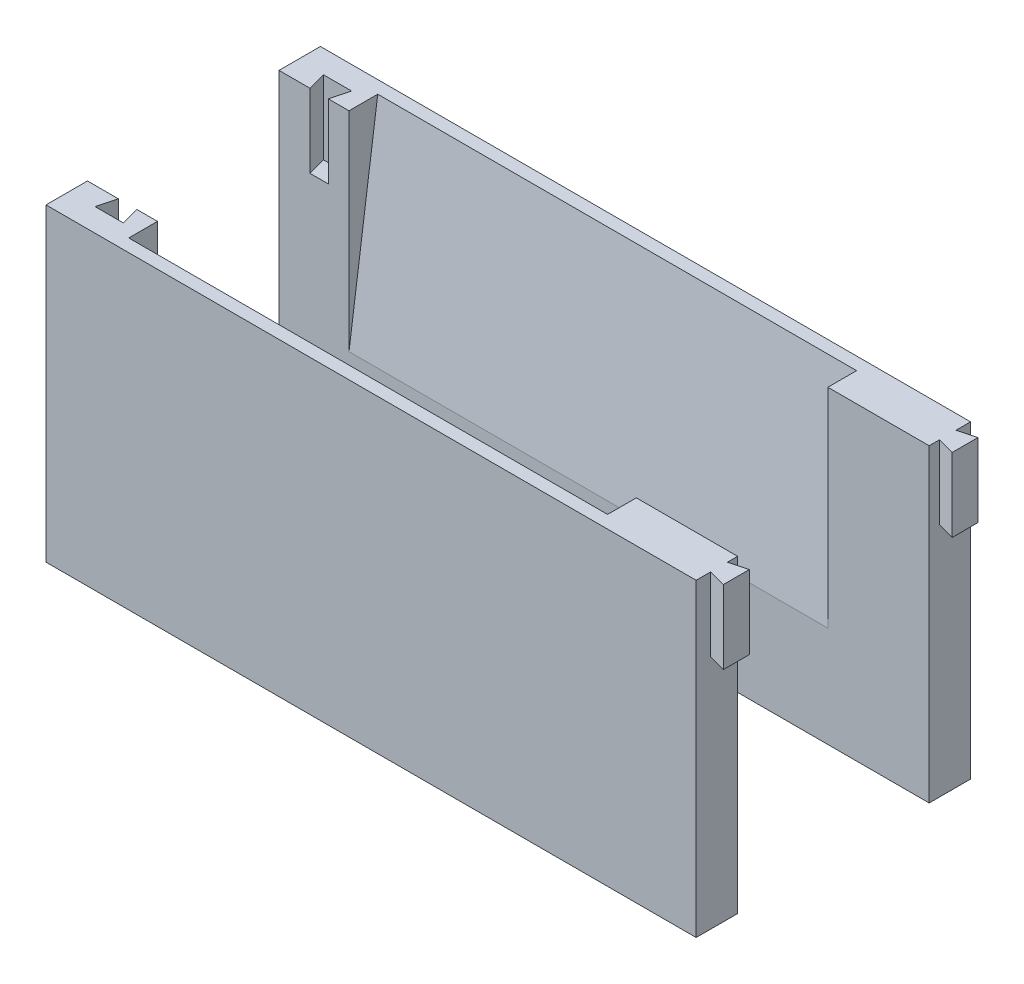
from build123d import *

# Parameters (mm, degrees)
SKETCH1_W               = 88.25
SKETCH1_H               = 42
BOSS_EXTRUDE1_DEPTH     = 5
CUT_EXTRUDE1_DEPTH      = 1
CUT_EXTRUDE1_DEPTH_BACK = 10
BOSS_EXTRUDE2_DEPTH     = 10
CUT_EXTRUDE2_DEPTH      = 65
SKETCH7_W               = 88.25
SKETCH7_H               = 0.63
SKETCH7_H_2             = 0.620319398
BOSS_EXTRUDE3_DEPTH     = 42


with BuildPart() as part:
    # Sketch1 → Boss-Extrude1 (new body)
    with BuildSketch(Plane.XY):
        with Locations((2.173974505, -6.951707737)):
            Rectangle(SKETCH1_W, SKETCH1_H)
    extrude(amount=BOSS_EXTRUDE1_DEPTH)

    # Sketch2 → Cut-Extrude1 (cut, two sides)
    with BuildSketch(Plane(origin=(0, 14.048292263, 0), x_dir=(1, 0, 0), z_dir=(0, 1, 0))) as cut_extrude1_sk:
        Polygon((-35.251025495, 0), (-37.751025495, 0), (-38.420898476, -2.5), (-34.581152514, -2.5), align=None)
    extrude(amount=CUT_EXTRUDE1_DEPTH, mode=Mode.SUBTRACT)
    extrude(cut_extrude1_sk.sketch, amount=-CUT_EXTRUDE1_DEPTH_BACK, mode=Mode.SUBTRACT)

    # Sketch3 → Boss-Extrude2 (add)
    with BuildSketch(Plane(origin=(0, 14.048292263, 0), x_dir=(1, 0, 0), z_dir=(0, 1, 0))):
        Polygon((46.298974505, -3.65), (48.648974505, -4.279680602), (48.648974505, -0.770319398), (46.298974505, -1.4), align=None)
    extrude(amount=-BOSS_EXTRUDE2_DEPTH)

    # Sketch6 → Cut-Extrude2 (cut)
    with BuildSketch(Plane.ZY.offset(32.451025495)):
        Polygon((-0.05, -14.629560467), (0, 14.048292263), (3.9, 14.048292263), align=None)
    extrude(amount=-CUT_EXTRUDE2_DEPTH, mode=Mode.SUBTRACT)


with BuildPart() as body_2:
    # Mirror3: mirrored copy
    add(part.part.mirror(Plane(origin=(0, 0, -13), x_dir=(1, 0, 0), z_dir=(0, 0, -1))))


with BuildPart() as part_1:
    add(part.part)

    add(body_2.part)  # Boss-Extrude3 merges body 2
    # Sketch7 → Boss-Extrude3 (add)
    with BuildSketch(Plane(origin=(0, 14.048292263, 0), x_dir=(1, 0, 0), z_dir=(0, 1, 0))):
        with Locations((2.173974505, -5.315)):
            Rectangle(SKETCH7_W, SKETCH7_H)
        with Locations((2.173974505, 31.310159699)):
            Rectangle(SKETCH7_W, SKETCH7_H_2)
    extrude(amount=-BOSS_EXTRUDE3_DEPTH)


solid = part_1.part
